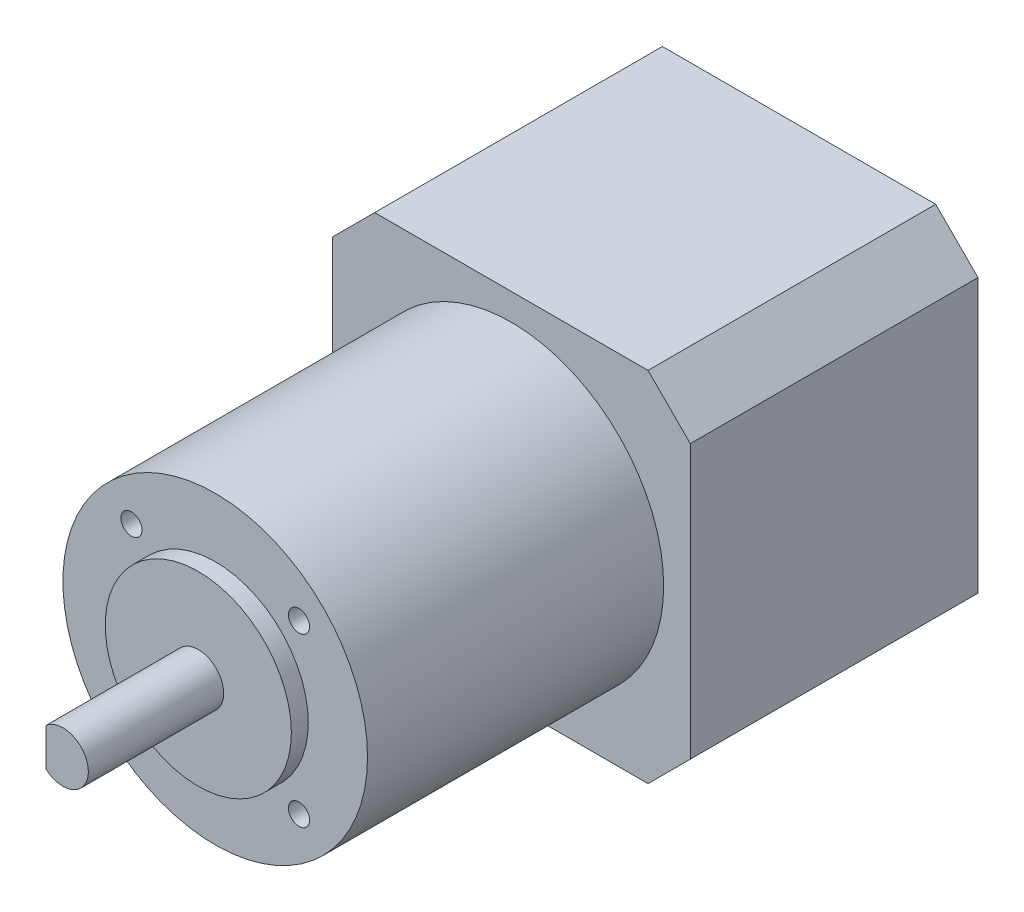
from build123d import *

# Parameters (mm, degrees)
SKETCH1_W                 = 42.3
SKETCH1_H                 = 42.3
BOSS_EXTRUDE1_DEPTH       = 34
SKETCH2_R                 = 18
BOSS_EXTRUDE2_DEPTH       = 35
SKETCH3_R                 = 11
BOSS_EXTRUDE3_DEPTH       = 2
SKETCH4_R                 = 3
BOSS_EXTRUDE4_DEPTH       = 16
CUT_EXTRUDE1_DEPTH        = 12
CHAMFER1_SIZE             = 5
M3X0_5_TAPPED_HOLE1_D     = 2.5
M3X0_5_TAPPED_HOLE1_DEPTH = 7.5
M3X0_5_TAPPED_HOLE1_TIP   = 0.751075774


with BuildPart() as part:
    # Sketch1 → Boss-Extrude1 (new body)
    with BuildSketch(Plane.XY):
        Rectangle(SKETCH1_W, SKETCH1_H)
    extrude(amount=BOSS_EXTRUDE1_DEPTH)

    # Sketch2 → Boss-Extrude2 (add)
    with BuildSketch(Plane.XY.offset(34)):
        Circle(SKETCH2_R)
    extrude(amount=BOSS_EXTRUDE2_DEPTH)

    # Sketch3 → Boss-Extrude3 (add)
    with BuildSketch(Plane.XY.offset(69)):
        Circle(SKETCH3_R)
    extrude(amount=BOSS_EXTRUDE3_DEPTH)

    # Sketch4 → Boss-Extrude4 (add)
    with BuildSketch(Plane.XY.offset(71)):
        Circle(SKETCH4_R)
    extrude(amount=BOSS_EXTRUDE4_DEPTH)

    # Sketch5 → Cut-Extrude1 (cut)
    with BuildSketch(Plane.XY.offset(87)):
        with BuildLine():
            Line((-2, 2.236067977), (-2, -2.236067977))
            ThreePointArc((-2, -2.236067977), (-3, 0), (-2, 2.236067977))
        make_face()
    extrude(amount=-CUT_EXTRUDE1_DEPTH, mode=Mode.SUBTRACT)

    # Chamfer1
    chamfer1_edges = [part.edges().sort_by_distance(p)[0] for p in [
        (-21.15, -21.15, 17),
        (21.15, -21.15, 17),
        (21.15, 21.15, 17),
        (-21.15, 21.15, 17),
    ]]
    chamfer(chamfer1_edges, length=CHAMFER1_SIZE)

    # M3x0.5 Tapped Hole1
    with Locations(Plane.XY.offset(69)):
        with Locations((-9.899494937, 9.899494937), (9.899494937, 9.899494937), (9.899494937, -9.899494937), (-9.899494937, -9.899494937)):
            Hole(M3X0_5_TAPPED_HOLE1_D / 2, depth=M3X0_5_TAPPED_HOLE1_DEPTH)
            with Locations((0, 0, -(M3X0_5_TAPPED_HOLE1_DEPTH + M3X0_5_TAPPED_HOLE1_TIP / 2))):  # 118° drill point
                Cone(0, M3X0_5_TAPPED_HOLE1_D / 2, M3X0_5_TAPPED_HOLE1_TIP, mode=Mode.SUBTRACT)


solid = part.part
